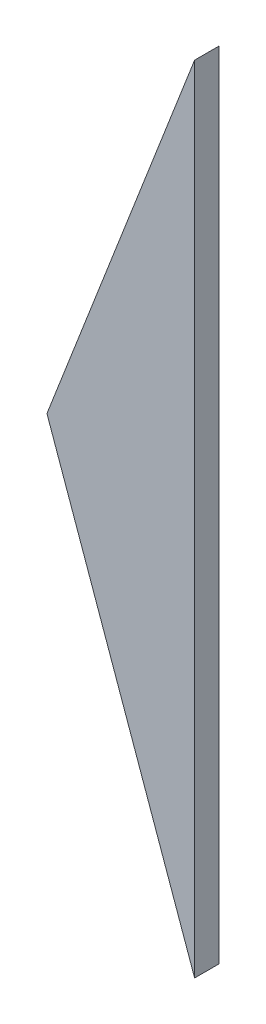
from build123d import *

# Parameters (mm, degrees)
BOSS_EXTRU_1_DEPTH = 3


with BuildPart() as part:
    # Esquisse1 → Boss.-Extru.1 (new body)
    with BuildSketch(Plane.XY):
        Polygon((-25.743066416, -66.222637248), (-7.62697721, -19.619983763), (-7.62697721, -117.134669828), align=None)
    extrude(amount=-BOSS_EXTRU_1_DEPTH)


solid = part.part
